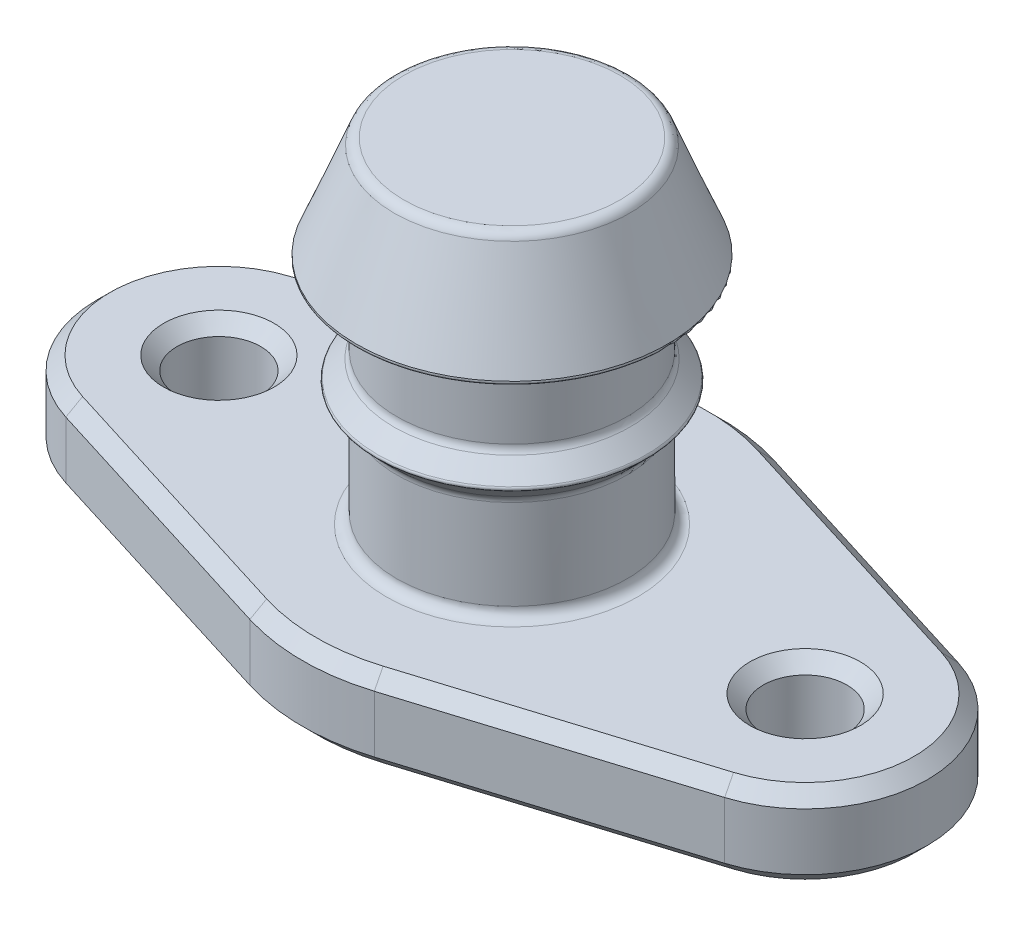
from build123d import *

# Parameters (mm, degrees)
SKETCH3_R           = 1.5875
BOSS_EXTRUDE2_DEPTH = 3.175
FILLET1_R           = 0.396875
FILLET2_R           = 0.09921875
CHAMFER1_SIZE       = 0.508


with BuildPart() as part:
    # Sketch1 → Revolve1 (revolve)
    with BuildSketch(Plane.XY):
        Polygon((0, 0), (7.9375, 0), (7.9375, 3.175), (4.365625, 3.175), (4.365625, 7.14375), (5.159375, 7.9375), (4.365625, 8.73125), (4.365625, 11.90625), (5.953125, 11.90625), (4.365625, 15.875), (0, 15.875), align=None)
    revolve(axis=Axis((0, 0, 0), (0, 1, 0)))

    # Sketch3 → Boss-Extrude2 (add)
    with BuildSketch(Plane.XZ):
        with BuildLine():
            Line((-12.489905714, 4.426128528), (-2.358571429, 7.578987206))
            ThreePointArc((-2.358571429, 7.578987206), (-5.442108037, 5.778180194), (-7.424238571, 2.807950834))
            ThreePointArc((-7.424238571, 2.807950834), (-7.808130375, 1.427237294), (-7.9375, 0))
            ThreePointArc((-7.9375, 0), (-7.808130375, -1.427237294), (-7.424238571, -2.807950834))
            ThreePointArc((-7.424238571, -2.807950834), (-5.442108037, -5.778180194), (-2.358571429, -7.578987206))
            Line((-2.358571429, -7.578987206), (-12.489905714, -4.426128528))
            ThreePointArc((-12.489905714, -4.426128528), (-15.748, 0), (-12.489905714, 4.426128528))
        make_face()
        with Locations((-11.1125, 0)):
            Circle(SKETCH3_R, mode=Mode.SUBTRACT)
        with BuildLine():
            Line((2.358571429, -7.578987206), (12.489905714, -4.426128528))
            ThreePointArc((12.489905714, -4.426128528), (15.748, 0), (12.489905714, 4.426128528))
            Line((12.489905714, 4.426128528), (2.358571429, 7.578987206))
            ThreePointArc((2.358571429, 7.578987206), (5.442108037, 5.778180194), (7.424238571, 2.807950834))
            ThreePointArc((7.424238571, 2.807950834), (7.808130375, 1.427237294), (7.9375, 0))
            ThreePointArc((7.9375, 0), (7.808130375, -1.427237294), (7.424238571, -2.807950834))
            ThreePointArc((7.424238571, -2.807950834), (5.442108037, -5.778180194), (2.358571429, -7.578987206))
        make_face()
        with Locations((11.1125, 0)):
            Circle(SKETCH3_R, mode=Mode.SUBTRACT)
    extrude(amount=-BOSS_EXTRUDE2_DEPTH)

    # Fillet1
    fillet1_edges = [part.edges().sort_by_distance(p)[0] for p in [
        (-4.365625, 11.90625, 0),
        (-4.365625, 8.73125, 0),
        (-4.365625, 7.14375, 0),
        (-4.365625, 3.175, 0),
        (-4.365625, 15.875, 0),
    ]]
    fillet(fillet1_edges, radius=FILLET1_R)

    # Fillet2
    fillet2_edges = [part.edges().sort_by_distance(p)[0] for p in [
        (-5.159375, 7.9375, 0),
        (-5.953125, 11.90625, 0),
    ]]
    fillet(fillet2_edges, radius=FILLET2_R)

    # Chamfer1
    chamfer1_edges = [part.edges().sort_by_distance(p)[0] for p in [
        (0, 3.175, 7.9375),
        (0, 0, 7.9375),
        (7.424238571, 3.175, 6.002557867),
        (15.748, 3.175, 0),
        (7.424238571, 3.175, -6.002557867),
        (9.525, 0, 0),
        (7.424238571, 0, -6.002557867),
        (15.748, 0, 0),
        (7.424238571, 0, 6.002557867),
        (9.525, 3.175, 0),
        (0, 3.175, -7.9375),
        (0, 0, -7.9375),
        (-7.424238571, 3.175, -6.002557867),
        (-15.748, 3.175, 0),
        (-7.424238571, 3.175, 6.002557867),
        (-12.7, 0, 0),
        (-7.424238571, 0, 6.002557867),
        (-15.748, 0, 0),
        (-7.424238571, 0, -6.002557867),
        (-12.7, 3.175, 0),
    ]]
    chamfer(chamfer1_edges, length=CHAMFER1_SIZE)


solid = part.part
